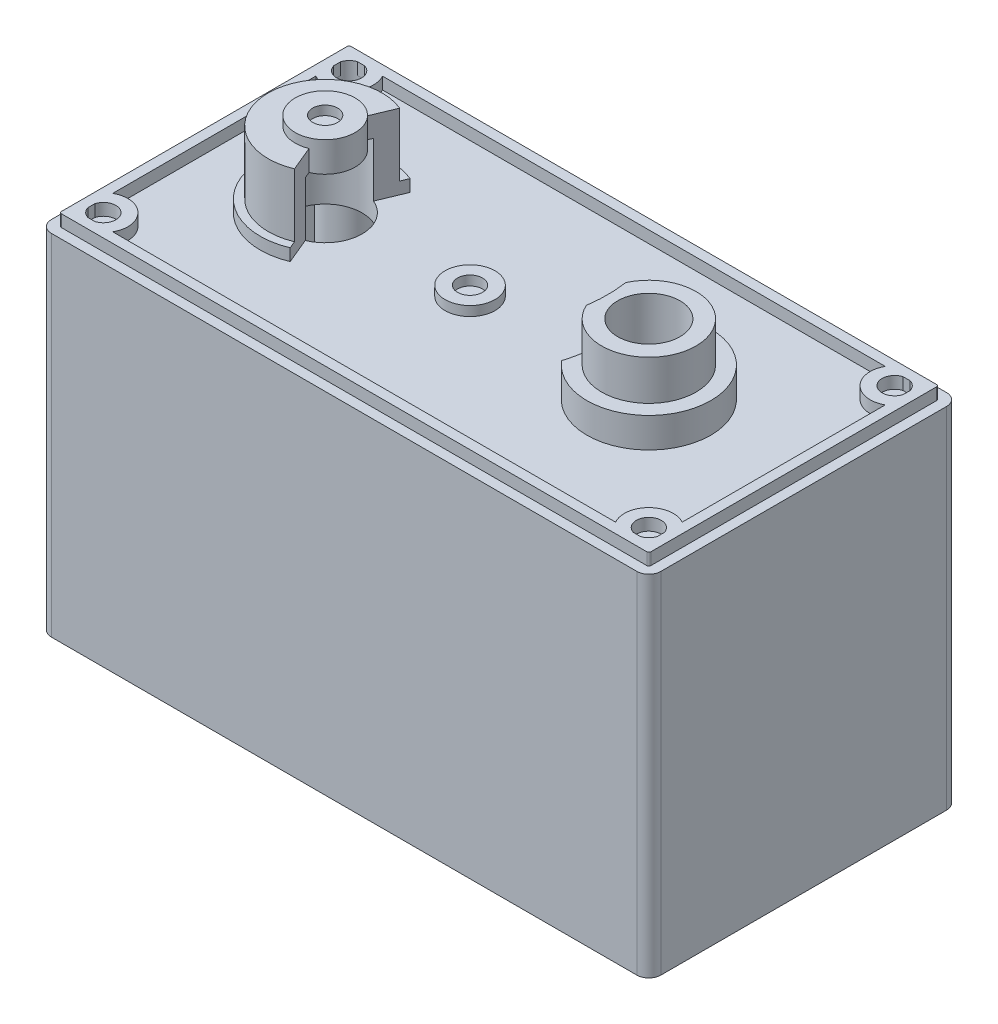
from build123d import *

# Parameters (mm, degrees)
SKETCH1_R                       = 2.3495
SKETCH1_R_2                     = 1.9812
EXTRUDE1_DEPTH                  = 1.190625
SKETCH6_R                       = 1.5875
SKETCH6_R_2                     = 0.79375
EXTRUDE3_DEPTH                  = 0.6096
SKETCH7_R                       = 3
SKETCH7_R_2                     = 1.9812
EXTRUDE4_DEPTH                  = 4.445
SKETCH16_R                      = 3.937
SKETCH16_R_2                    = 3
EXTRUDE11_DEPTH                 = 1.905
CUT_EXTRUDE1_REACH              = 24.444
SKETCH11_R                      = 7.874
SKETCH11_R_2                    = 6.604
EXTRUDE6_DEPTH                  = 4.572
SKETCH10_W                      = 37.211
SKETCH10_H                      = 18.161
EXTRUDE5_DEPTH                  = 22.225
SKETCH13_W                      = 1.143
SKETCH13_H                      = 3.048
EXTRUDE8_DEPTH                  = 10.795
EXTRUDE9_START                  = -1.952625
SKETCH14_R                      = 0.79375
EXTRUDE9_DEPTH                  = 22.987
SKETCH23_R                      = 0.79375
CUT_EXTRUDE2_DEPTH              = 1.190625
CUT_EXTRUDE3_REACH              = 36.655
MIRROR2_START                   = -1.952625
MIRROR2_COPY_1_SKETCH_R         = 0.79375
MIRROR2_COPY_1_DEPTH            = 22.987
SKETCH18_W                      = 36.195
SKETCH18_H                      = 17.145
EXTRUDE12_DEPTH                 = 0.762
SKETCH19_R                      = 2.54
EXTRUDE13_DEPTH                 = 1.905
EXTRUDE14_DEPTH                 = 5.588
F_1_64_TAPPED_HOLE1_D           = 1.5113
F_1_64_TAPPED_HOLE1_DEPTH       = 5.588
F_1_64_TAPPED_HOLE1_CBORE_D     = 1.8542
F_1_64_TAPPED_HOLE1_CBORE_DEPTH = 3.7084


with BuildPart() as part:
    # Sketch1 → Extrude1 (new body)
    with BuildSketch(Plane(origin=(0, 0, 0), x_dir=(1, 0, 0), z_dir=(0, 1, 0))):
        with BuildLine():
            Line((-18.6055, 9.8425), (18.6055, 9.8425))
            ThreePointArc((18.6055, 9.8425), (19.144315367, 9.619315367), (19.3675, 9.0805))
            Line((19.3675, 9.0805), (19.3675, -9.0805))
            ThreePointArc((19.3675, -9.0805), (19.144315367, -9.619315367), (18.6055, -9.8425))
            Line((18.6055, -9.8425), (-18.6055, -9.8425))
            ThreePointArc((-18.6055, -9.8425), (-19.144315367, -9.619315367), (-19.3675, -9.0805))
            Line((-19.3675, -9.0805), (-19.3675, 9.0805))
            ThreePointArc((-19.3675, 9.0805), (-19.144315367, 9.619315367), (-18.6055, 9.8425))
        make_face()
        with Locations(Location((-11.049, 0, 0), (0, 0, 90))):
            Circle(SKETCH1_R, mode=Mode.SUBTRACT)
        with Locations(Location((9.525, 0, 0), (0, 0, 90))):
            Circle(SKETCH1_R_2, mode=Mode.SUBTRACT)
    extrude(amount=EXTRUDE1_DEPTH)

    # Sketch6 → Extrude3 (add)
    with BuildSketch(Plane(origin=(0, 1.190625, 0), x_dir=(-1, 0, 0), z_dir=(0, 1, 0))):
        with Locations(Location((1.8415, 0, 0), (0, 0, 270))):
            Circle(SKETCH6_R)
        with Locations(Location((1.8415, 0, 0), (0, 0, 90))):
            Circle(SKETCH6_R_2, mode=Mode.SUBTRACT)
    extrude(amount=EXTRUDE3_DEPTH)

    # Sketch7 → Extrude4 (add)
    with BuildSketch(Plane(origin=(0, 1.190625, 0), x_dir=(-1, 0, 0), z_dir=(0, 1, 0))):
        with Locations(Location((-9.525, 0, 0), (0, 0, 270))):
            Circle(SKETCH7_R)
        with Locations(Location((-9.525, 0, 0), (0, 0, 270))):
            Circle(SKETCH7_R_2, mode=Mode.SUBTRACT)
    extrude(amount=EXTRUDE4_DEPTH)

    # Sketch16 → Extrude11 (add)
    with BuildSketch(Plane(origin=(0, 1.190625, 0), x_dir=(-1, 0, 0), z_dir=(0, 1, 0))):
        with Locations(Location((-9.525, 0, 0), (0, 0, 270))):
            Circle(SKETCH16_R)
        with Locations(Location((-9.525, 0, 0), (0, 0, 90))):
            Circle(SKETCH16_R_2, mode=Mode.SUBTRACT)
    extrude(amount=EXTRUDE11_DEPTH)

    # Cut-Extrude1: up to this face of the body (flat: up to its plane)
    cut_extrude1_end = Plane(part.part.faces().sort_by_distance((0, 1.190625, -9.408000351))[0])
    # Sketch17 → Cut-Extrude1 (cut, up to the picked face)
    with BuildSketch(Plane(origin=(0, 5.635625, 0), x_dir=(-1, 0, 0), z_dir=(0, 1, 0)), mode=Mode.PRIVATE) as cut_extrude1_sk1:
        with BuildLine():
            ThreePointArc((-6.516949302, 2.54), (-6.894361419, 0), (-6.516949302, -2.54))
            ThreePointArc((-6.516949302, -2.54), (-5.588, 0), (-6.516949302, 2.54))
        make_face()
    cut_extrude1_tool1 = split(extrude(cut_extrude1_sk1.sketch, amount=-CUT_EXTRUDE1_REACH, mode=Mode.PRIVATE), bisect_by=cut_extrude1_end, keep=Keep.BOTH, mode=Mode.PRIVATE)
    add(cut_extrude1_tool1.solids().sort_by(Axis((6.291228, 5.635625, 0), (0, -1, 0)))[0], mode=Mode.SUBTRACT)

    # Sketch11 → Extrude6 (add)
    with BuildSketch(Plane.XZ):
        with Locations(Location((9.525, 0, 0), (0, 0, 270))):
            Circle(SKETCH11_R)
        with Locations(Location((9.525, 0, 0), (0, 0, 270))):
            Circle(SKETCH11_R_2, mode=Mode.SUBTRACT)
    extrude(amount=EXTRUDE6_DEPTH)

    # Sketch10 → Extrude5 (add)
    with BuildSketch(Plane.XZ.offset(-1.190625)):
        with BuildLine():
            Line((-19.3675, 9.0805), (-19.3675, -9.0805))
            ThreePointArc((-19.3675, -9.0805), (-19.144315367, -9.619315367), (-18.6055, -9.8425))
            Line((-18.6055, -9.8425), (18.6055, -9.8425))
            ThreePointArc((18.6055, -9.8425), (19.144315367, -9.619315367), (19.3675, -9.0805))
            Line((19.3675, -9.0805), (19.3675, 9.0805))
            ThreePointArc((19.3675, 9.0805), (19.144315367, 9.619315367), (18.6055, 9.8425))
            Line((18.6055, 9.8425), (-18.6055, 9.8425))
            ThreePointArc((-18.6055, 9.8425), (-19.144315367, 9.619315367), (-19.3675, 9.0805))
        make_face()
        Rectangle(SKETCH10_W, SKETCH10_H, mode=Mode.SUBTRACT)
    extrude(amount=EXTRUDE5_DEPTH)

    # Sketch13 → Extrude8 (add)
    with BuildSketch(Plane.XZ):
        with BuildLine():
            Line((-5.9055, 6.0325), (-5.9055, 9.0805))
            Line((-5.9055, 9.0805), (-4.7625, 9.0805))
            Line((-4.7625, 9.0805), (-4.7625, 6.713831938))
            ThreePointArc((-4.7625, 6.713831938), (-1.851412189, 0), (-4.7625, -6.713831938))
            Line((-4.7625, -6.713831938), (-4.7625, -9.0805))
            Line((-4.7625, -9.0805), (-5.9055, -9.0805))
            Line((-5.9055, -9.0805), (-5.9055, -6.0325))
            ThreePointArc((-5.9055, -6.0325), (-3.121412189, 0), (-5.9055, 6.0325))
        make_face()
        with Locations((-8.382, 7.5565)):
            Rectangle(SKETCH13_W, SKETCH13_H)
        with Locations((-13.335, 7.5565)):
            Rectangle(SKETCH13_W, SKETCH13_H)
        with Locations((-13.335, -7.5565)):
            Rectangle(SKETCH13_W, SKETCH13_H)
        with Locations((-8.382, -7.5565)):
            Rectangle(SKETCH13_W, SKETCH13_H)
    extrude(amount=EXTRUDE8_DEPTH)

    # Sketch14 → Extrude9 (add)
    with BuildSketch(Plane.XZ.offset(EXTRUDE9_START)):
        with BuildLine():
            Line((-18.6055, -9.0805), (-18.6055, -6.911913297))
            ThreePointArc((-18.6055, -6.911913297), (-16.235418625, -6.710418625), (-16.436913297, -9.0805))
            Line((-16.436913297, -9.0805), (-18.6055, -9.0805))
        make_face()
        with Locations(Location((-17.3355, -7.8105, 0), (0, 0, 270))):
            Circle(SKETCH14_R, mode=Mode.SUBTRACT)
    extrude9 = extrude(amount=EXTRUDE9_DEPTH)

    # Sketch23 → Cut-Extrude2 (cut)
    with BuildSketch(Plane(origin=(0, 1.190625, 0), x_dir=(-1, 0, 0), z_dir=(0, 1, 0))):
        with Locations(Location((17.3355, -7.8105, 0), (0, 0, 270))):
            Circle(SKETCH23_R)
    extrude(amount=-CUT_EXTRUDE2_DEPTH, mode=Mode.SUBTRACT)

    # Sketch9 → Revolve1 (revolve)
    with BuildSketch(Plane.XY, mode=Mode.PRIVATE) as revolve1_sk:
        Polygon((-12.954, 5.965825), (-12.954, 6.550025), (-11.84275, 6.550025), (-11.84275, 5.965825), (-11.049, 5.965825), (-11.049, 4.645025), (-13.3985, 4.645025), (-13.3985, 1.190625), (-15.1765, 1.190625), (-15.1765, 1.952625), (-14.6685, 1.952625), (-14.6685, 5.965825), align=None)
    revolve(revolve1_sk.sketch.rotate(Axis((-11.049, 0, 0), (0, 1, 0)), 270), axis=Axis((-11.049, 0, 0), (0, 1, 0)))

    # Cut-Extrude3: up to this face of the body (flat: up to its plane)
    cut_extrude3_end = Plane(part.part.faces().sort_by_distance((-1.8415, 1.190625, 0))[0])
    # Sketch24 → Cut-Extrude3 (cut, up to the picked face)
    with BuildSketch(Plane(origin=(0, 5.965825, 0), x_dir=(-1, 0, 0), z_dir=(0, 1, 0)), mode=Mode.PRIVATE) as cut_extrude3_sk1:
        with BuildLine():
            Line((10.316307692, 1.758461538), (9.4615, 3.81))
            ThreePointArc((9.4615, 3.81), (6.9215, 0), (9.4615, -3.81))
            Line((9.4615, -3.81), (10.316307692, -1.758461538))
            ThreePointArc((10.316307692, -1.758461538), (9.144, 0), (10.316307692, 1.758461538))
        make_face()
    cut_extrude3_tool1 = split(extrude(cut_extrude3_sk1.sketch, amount=-CUT_EXTRUDE3_REACH, mode=Mode.PRIVATE), bisect_by=cut_extrude3_end, keep=Keep.BOTH, mode=Mode.PRIVATE)
    add(cut_extrude3_tool1.solids().sort_by(Axis((-8.574349, 5.965825, 0), (0, -1, 0)))[0], mode=Mode.SUBTRACT)

    # Mirror1: Extrude9 across plane
    add(extrude9.mirror(Plane(origin=(0, 0, 0), x_dir=(0, 0, 1), z_dir=(1, 0, 0))))

    # Mirror2: Extrude9 across plane
    add(extrude9.mirror(Plane.XY))

    # Mirror2 copy 1 sketch → Mirror2 copy 1 (add)
    with BuildSketch(Plane(origin=(0, 0, 0), x_dir=(-1, 0, 0), z_dir=(0, -1, 0)).offset(MIRROR2_START)):
        with BuildLine():
            Line((-18.6055, -9.0805), (-18.6055, -6.911913297))
            ThreePointArc((-18.6055, -6.911913297), (-16.235418625, -6.710418625), (-16.436913297, -9.0805))
            Line((-16.436913297, -9.0805), (-18.6055, -9.0805))
        make_face()
        with Locations(Location((-17.3355, -7.8105, 0), (0, 0, 270))):
            Circle(MIRROR2_COPY_1_SKETCH_R, mode=Mode.SUBTRACT)
    extrude(amount=MIRROR2_COPY_1_DEPTH)

    # Sketch18 → Extrude12 (add)
    with BuildSketch(Plane(origin=(0, 1.952625, 0), x_dir=(-1, 0, 0), z_dir=(0, 1, 0))):
        with BuildLine():
            Line((18.6055, 9.2075), (-18.6055, 9.2075))
            ThreePointArc((-18.6055, 9.2075), (-18.695302561, 9.170302561), (-18.7325, 9.0805))
            Line((-18.7325, 9.0805), (-18.7325, -9.0805))
            ThreePointArc((-18.7325, -9.0805), (-18.695302561, -9.170302561), (-18.6055, -9.2075))
            Line((-18.6055, -9.2075), (18.6055, -9.2075))
            ThreePointArc((18.6055, -9.2075), (18.695302561, -9.170302561), (18.7325, -9.0805))
            Line((18.7325, -9.0805), (18.7325, 9.0805))
            ThreePointArc((18.7325, 9.0805), (18.695302561, 9.170302561), (18.6055, 9.2075))
        make_face()
        Rectangle(SKETCH18_W, SKETCH18_H, mode=Mode.SUBTRACT)
    extrude(amount=-EXTRUDE12_DEPTH)

    # Sketch19 → Extrude13 (add)
    with BuildSketch(Plane.XZ):
        with BuildLine():
            Line((11.557, -3.222898695), (11.557, -6.283612973))
            ThreePointArc((11.557, -6.283612973), (11.178939296, -6.393535861), (10.795, -6.480734218))
            Line((10.795, -6.480734218), (10.795, -3.592102448))
            ThreePointArc((10.795, -3.592102448), (9.525, -3.81), (8.255, -3.592102448))
            Line((8.255, -3.592102448), (8.255, -6.480734218))
            ThreePointArc((8.255, -6.480734218), (7.871060704, -6.393535861), (7.493, -6.283612973))
            Line((7.493, -6.283612973), (7.493, -3.222898695))
            ThreePointArc((7.493, -3.222898695), (9.525, 3.81), (11.557, -3.222898695))
        make_face()
        with Locations(Location((9.525, 0, 0), (0, 0, 90))):
            Circle(SKETCH19_R, mode=Mode.SUBTRACT)
    extrude(amount=EXTRUDE13_DEPTH)

    # Sketch20 → Extrude14 (add)
    with BuildSketch(Plane.XZ):
        with BuildLine():
            ThreePointArc((4.320531036, -4.065257532), (3.147336001, -7.413112903), (6.282470752, -5.753157401))
            ThreePointArc((6.282470752, -5.753157401), (5.218006131, -5.006258065), (4.320531036, -4.065257532))
        make_face()
    extrude(amount=EXTRUDE14_DEPTH)

    # 1-64 Tapped Hole1
    with Locations(Plane(origin=(4.389738079, -5.588, -5.969), x_dir=(0, 0, -1), z_dir=(0, -1, 0))):
        with Locations((0, 0)):
            CounterBoreHole(F_1_64_TAPPED_HOLE1_D / 2, F_1_64_TAPPED_HOLE1_CBORE_D / 2, F_1_64_TAPPED_HOLE1_CBORE_DEPTH, depth=F_1_64_TAPPED_HOLE1_DEPTH)


solid = part.part
